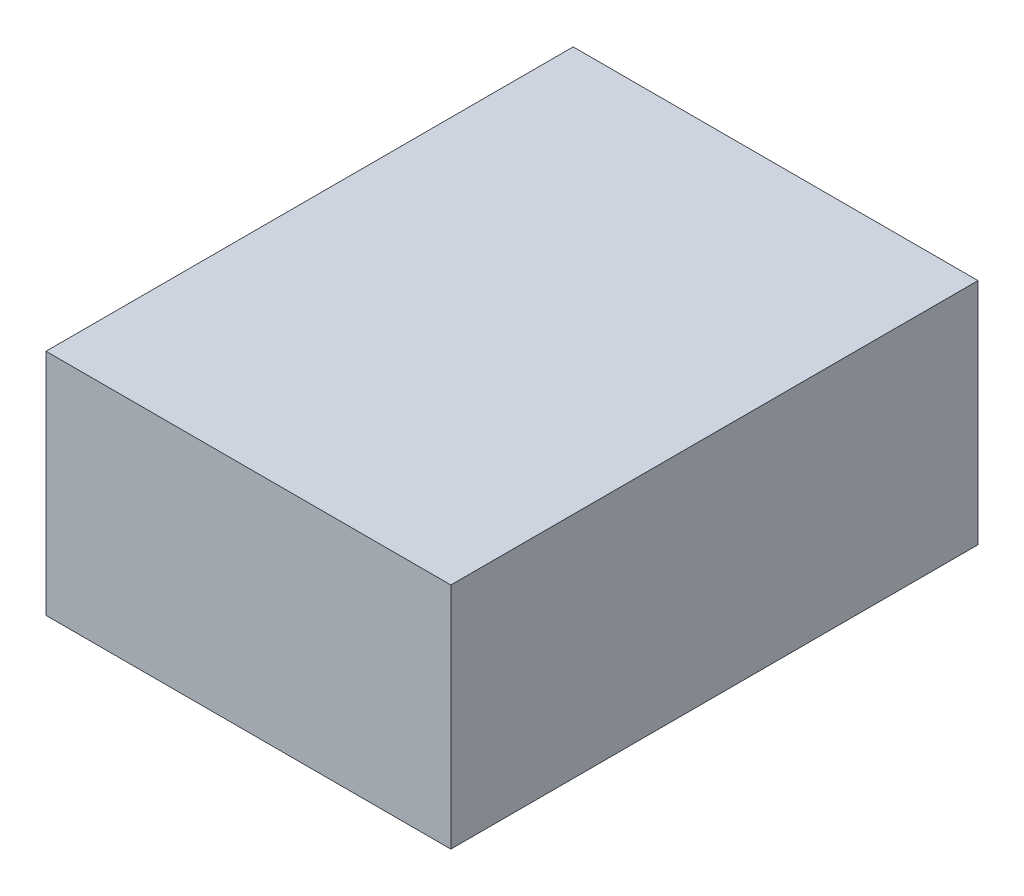
from build123d import *

# Parameters (mm, degrees)
IZIM1_W                          = 103.378
IZIM1_H                          = 58.42
Y_KSEKLIK_EKSTR_ZYON1_DEPTH      = 67.31
Y_KSEKLIK_EKSTR_ZYON1_DEPTH_BACK = 67.31


with BuildPart() as part:
    # Çizim1 → Yükseklik-Ekstrüzyon1 (new body, two sides)
    with BuildSketch(Plane.XY) as y_kseklik_ekstr_zyon1_sk:
        Rectangle(IZIM1_W, IZIM1_H)
    extrude(amount=Y_KSEKLIK_EKSTR_ZYON1_DEPTH)
    extrude(y_kseklik_ekstr_zyon1_sk.sketch, amount=-Y_KSEKLIK_EKSTR_ZYON1_DEPTH_BACK)


solid = part.part
